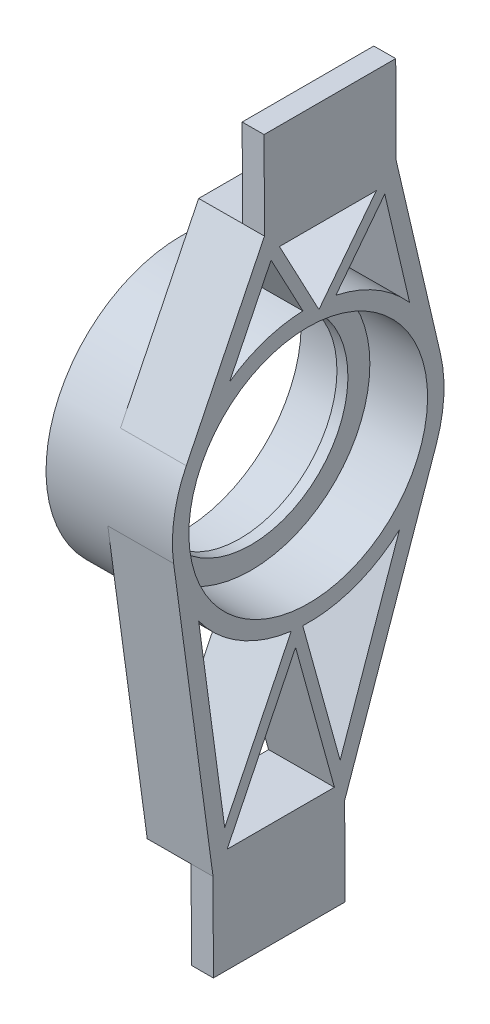
from build123d import *

# Parameters (mm, degrees)
SKETCH1_R                = 34.544
BOSS_EXTRUDE1_DEPTH      = 6.35
BOSS_EXTRUDE1_DEPTH_BACK = 12.7
CUT_EXTRUDE1_START       = -12.7
SKETCH2_W                = 38.1
SKETCH2_H                = 25.4
CUT_EXTRUDE1_DEPTH       = 12.7
SKETCH3_R                = 39.3065
SKETCH3_R_2              = 34.544
BOSS_EXTRUDE2_DEPTH      = 17.526
SKETCH4_R                = 34.544
SKETCH4_R_2              = 28.194
BOSS_EXTRUDE3_DEPTH      = 1.5875


with BuildPart() as part:
    # Sketch1 → Boss-Extrude1 (new body, two sides)
    with BuildSketch(Plane(origin=(648.29757997, 2.828749778, 0), x_dir=(0, 0, -1), z_dir=(0.999990481, 0.004363309, 0))) as boss_extrude1_sk:
        with BuildLine():
            Line((10.162421384, 149.738796817), (10.162421384, 124.338796817))
            Line((10.162421384, 124.338796817), (-27.937578616, 124.338796817))
            Line((-27.937578616, 124.338796817), (-27.937578616, 149.738796817))
            Line((-27.937578616, 149.738796817), (-38.969975232, 233.506353672))
            ThreePointArc((-38.969975232, 233.506353672), (-38.774533686, 245.083676928), (-35.214302621, 256.101724211))
            Line((-35.214302621, 256.101724211), (-12.384316038, 302.138796817))
            Line((-12.384316038, 302.138796817), (-12.384316038, 327.538796817))
            Line((-12.384316038, 327.538796817), (25.715683962, 327.538796817))
            Line((25.715683962, 327.538796817), (25.715683962, 302.138796817))
            Line((25.715683962, 302.138796817), (38.304504923, 247.457291294))
            ThreePointArc((38.304504923, 247.457291294), (39.241875136, 236.385759301), (37.043517063, 225.49426237))
            Line((37.043517063, 225.49426237), (10.162421384, 149.738796817))
        make_face()
        with Locations((0, 238.638796817)):
            Circle(SKETCH1_R, mode=Mode.SUBTRACT)
        with BuildLine():
            Line((22.400354986, 295.311648337), (29.455908243, 264.664753318))
            ThreePointArc((29.455908243, 264.664753318), (19.813317438, 272.586306215), (8.173615245, 277.086071832))
            Line((8.173615245, 277.086071832), (22.400354986, 295.311648337))
        make_face(mode=Mode.SUBTRACT)
        with BuildLine():
            Line((-1.363444644, 277.921642449), (-10.508730274, 295.201256573))
            Line((-10.508730274, 295.201256573), (-22.615671737, 270.787394518))
            ThreePointArc((-22.615671737, 270.787394518), (-12.508951954, 275.901741725), (-1.363444644, 277.921642449))
        make_face(mode=Mode.SUBTRACT)
        Polygon((19.984225718, 297.376296817), (3.266942404, 275.960137419), (-8.067621746, 297.376296817), align=None, mode=Mode.SUBTRACT)
        with BuildLine():
            Line((26.283654933, 209.412602647), (8.894198101, 160.406177697))
            Line((8.894198101, 160.406177697), (-1.749435192, 199.371247635))
            ThreePointArc((-1.749435192, 199.371247635), (13.254779787, 201.63458415), (26.283654933, 209.412602647))
        make_face(mode=Mode.SUBTRACT)
        with BuildLine():
            Line((-5.104730105, 199.665181732), (-24.520278978, 160.264997004))
            Line((-24.520278978, 160.264997004), (-31.799445858, 215.534767182))
            ThreePointArc((-31.799445858, 215.534767182), (-20.085828001, 204.851810331), (-5.104730105, 199.665181732))
        make_face(mode=Mode.SUBTRACT)
        Polygon((-3.852902363, 195.022655751), (7.215844228, 154.501296817), (-23.820941352, 154.501296817), align=None, mode=Mode.SUBTRACT)
    extrude(amount=BOSS_EXTRUDE1_DEPTH)
    extrude(boss_extrude1_sk.sketch, amount=-BOSS_EXTRUDE1_DEPTH_BACK)

    # Sketch2 → Cut-Extrude1 (cut)
    with BuildSketch(Plane(origin=(635.597700865, 2.77333575, 0), x_dir=(0, 0, 1), z_dir=(-0.999990481, -0.004363309, 0)).offset(CUT_EXTRUDE1_START)):
        with Locations((-6.665683962, 314.838796817)):
            Rectangle(SKETCH2_W, SKETCH2_H)
        with Locations((8.887578616, 137.038796817)):
            Rectangle(SKETCH2_W, SKETCH2_H)
    extrude(amount=CUT_EXTRUDE1_DEPTH, mode=Mode.SUBTRACT)

    # Sketch3 → Boss-Extrude2 (add)
    with BuildSketch(Plane(origin=(635.597700865, 2.77333575, 0), x_dir=(0, 0, 1), z_dir=(-0.999990481, -0.004363309, 0))):
        with Locations((0, 238.638796817)):
            Circle(SKETCH3_R)
        with Locations((0, 238.638796817)):
            Circle(SKETCH3_R_2, mode=Mode.SUBTRACT)
    extrude(amount=BOSS_EXTRUDE2_DEPTH)

    # Sketch4 → Boss-Extrude3 (add, symmetric)
    with BuildSketch(Plane(origin=(636.359693611, 2.776660591, 0), x_dir=(0, 0, 1), z_dir=(-0.999990481, -0.004363309, 0))):
        with Locations((0, 238.638796817)):
            Circle(SKETCH4_R)
        with Locations((0, 238.638796817)):
            Circle(SKETCH4_R_2, mode=Mode.SUBTRACT)
    extrude(amount=BOSS_EXTRUDE3_DEPTH, both=True)


solid = part.part
